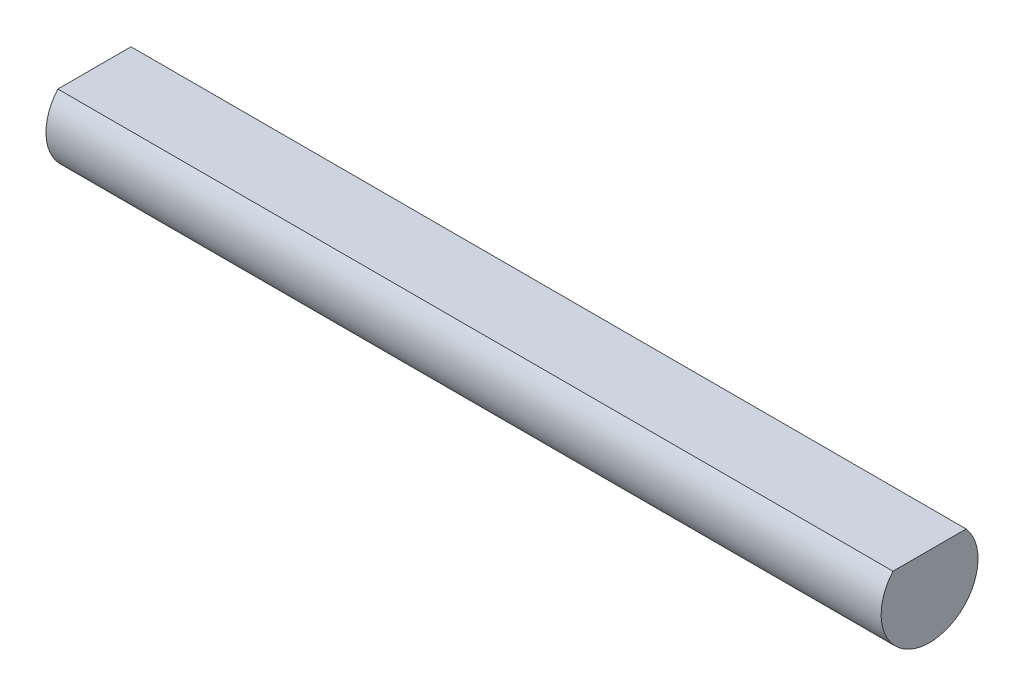
from build123d import *

# Parameters (mm, degrees)
BOSS_EXTRUDE1_DEPTH      = 12.5
BOSS_EXTRUDE1_DEPTH_BACK = 12.5


with BuildPart() as part:
    # Sketch1 → Boss-Extrude1 (new, two sides: drawn at the far end of the back side and taken through both)
    with BuildSketch(Plane(origin=(0, 0, 0), x_dir=(0, 0, -1), z_dir=(1, 0, 0)).offset(-BOSS_EXTRUDE1_DEPTH_BACK)):
        with BuildLine():
            ThreePointArc((-1.095445115, 0.95), (0, -1.45), (1.095445115, 0.95))
            Line((1.095445115, 0.95), (-1.095445115, 0.95))
        make_face()
    extrude(amount=BOSS_EXTRUDE1_DEPTH + BOSS_EXTRUDE1_DEPTH_BACK)


solid = part.part
